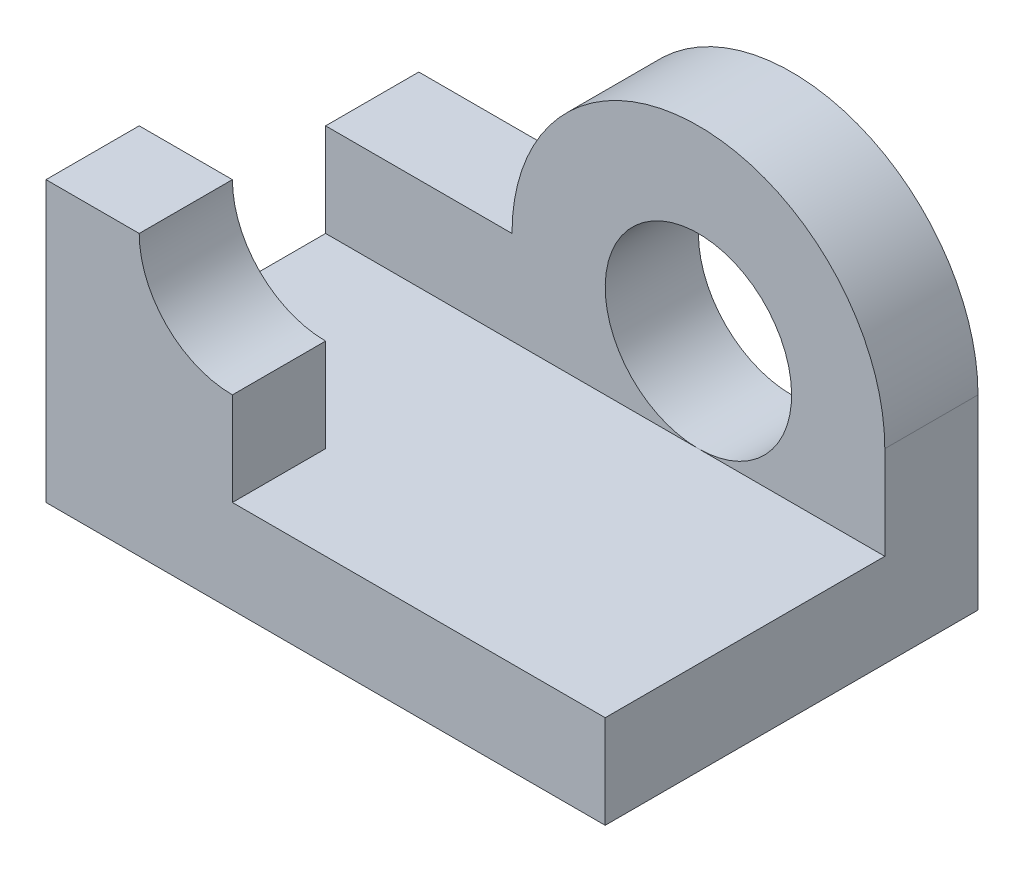
from build123d import *

# Parameters (mm, degrees)
SKETCH_1_R      = 1
EXTRUDE_1_DEPTH = 1
SKETCH_1_6_W    = 6
SKETCH_1_6_H    = 1
EXTRUDE_3_DEPTH = 4
EXTRUDE_START   = 3
EXTRUDE_4_DEPTH = 1


with BuildPart() as part:
    # 草圖1 → 填料-伸長1 (new body)
    with BuildSketch(Plane.XY):
        with BuildLine():
            ThreePointArc((2, 2), (0, 4), (-2, 2))
            Line((-2, 2), (-4, 2))
            Line((-4, 2), (-4, 0))
            Line((-4, 0), (2, 0))
            Line((2, 0), (2, 2))
        make_face()
        with Locations((0, 2)):
            Circle(SKETCH_1_R, mode=Mode.SUBTRACT)
    extrude(amount=EXTRUDE_1_DEPTH)

    # 草圖1<6> → 填料-伸長3 (add)
    with BuildSketch(Plane.XY):
        with Locations((-1, 0.5)):
            Rectangle(SKETCH_1_6_W, SKETCH_1_6_H)
    extrude(amount=EXTRUDE_3_DEPTH)

    # 草圖1<7> → 填料-伸長4 (add)
    with BuildSketch(Plane.XY.offset(EXTRUDE_START)):
        with BuildLine():
            Line((-2, 1), (-2, 2))
            ThreePointArc((-2, 2), (-2.707106781, 2.292893219), (-3, 3))
            Line((-3, 3), (-4, 3))
            Line((-4, 3), (-4, 1))
            Line((-4, 1), (-2, 1))
        make_face()
    extrude(amount=EXTRUDE_4_DEPTH)


solid = part.part
